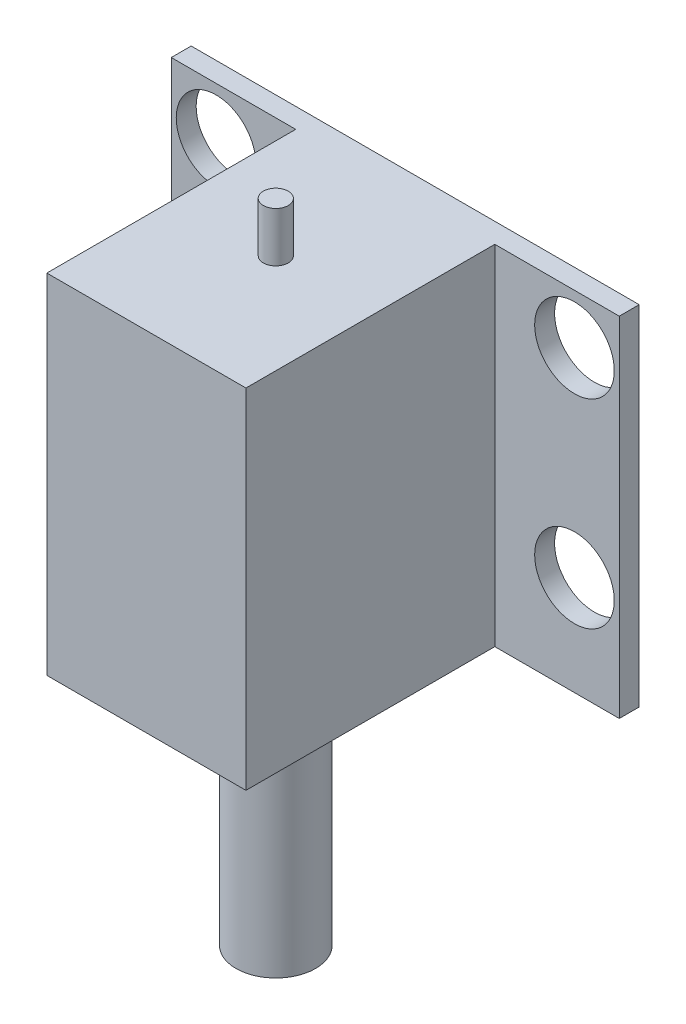
from build123d import *

# Parameters (mm, degrees)
SKETCH_1_W          = 45
SKETCH_1_H          = 35
EXTRUDE_1_DEPTH     = 2
SKETCH_2_W          = 20
SKETCH_2_H          = 35
EXTRUDE_2_DEPTH     = 25
SKETCH_3_R          = 4
EXTRUDE_3_DEPTH     = 25
SKETCH_4_R          = 1.25
EXTRUDE_4_DEPTH     = 5
SKETCH_5_R          = 4
CUT_EXTRUDE_1_DEPTH = 28


with BuildPart() as part:
    # ｽｹｯﾁ1 → ﾎﾞｽ - 押し出し1 (new body)
    with BuildSketch(Plane.XY):
        Rectangle(SKETCH_1_W, SKETCH_1_H)
    extrude(amount=EXTRUDE_1_DEPTH)

    # ｽｹｯﾁ2 → ﾎﾞｽ - 押し出し2 (add)
    with BuildSketch(Plane.XY.offset(2)):
        Rectangle(SKETCH_2_W, SKETCH_2_H)
    extrude(amount=EXTRUDE_2_DEPTH)

    # ｽｹｯﾁ3 → ﾎﾞｽ - 押し出し3 (add)
    with BuildSketch(Plane(origin=(0, -17.5, 0), x_dir=(-1, 0, 0), z_dir=(0, -1, 0))):
        with Locations((0, -14)):
            Circle(SKETCH_3_R)
    extrude(amount=EXTRUDE_3_DEPTH)

    # ｽｹｯﾁ4 → ﾎﾞｽ - 押し出し4 (add)
    with BuildSketch(Plane(origin=(0, 17.5, 0), x_dir=(1, 0, 0), z_dir=(0, 1, 0))):
        with Locations((0, -14)):
            Circle(SKETCH_4_R)
    extrude(amount=EXTRUDE_4_DEPTH)

    # ｽｹｯﾁ5 → ｶｯﾄ - 押し出し1 (cut, through all)
    with BuildSketch(Plane(origin=(0, 0, 0), x_dir=(-1, 0, 0), z_dir=(0, 0, -1))):
        with Locations((18, -7.5)):
            Circle(SKETCH_5_R)
        with Locations((18, 12.5)):
            Circle(SKETCH_5_R)
        with Locations((-18, 12.5)):
            Circle(SKETCH_5_R)
        with Locations((-18, -7.5)):
            Circle(SKETCH_5_R)
    extrude(amount=-CUT_EXTRUDE_1_DEPTH, mode=Mode.SUBTRACT)


solid = part.part
